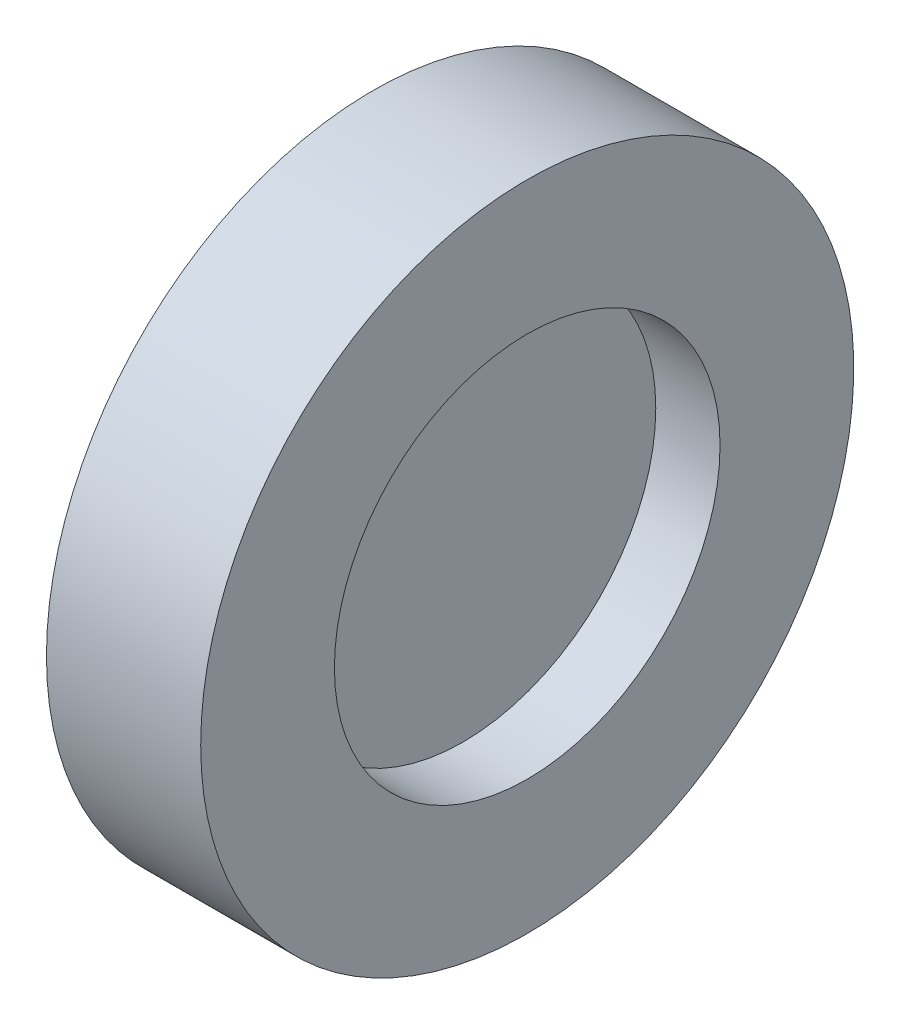
from build123d import *

# Parameters (mm, degrees)
SKETCH_1_W = 1
SKETCH_1_H = 7.5
SKETCH_4_W = 6
SKETCH_4_H = 5.2


with BuildPart() as part:
    # 草图1 → 旋转2 (revolve)
    with BuildSketch(Plane.XY, mode=Mode.PRIVATE) as revolve_2_sk:
        with Locations((0, 3.75)):
            Rectangle(SKETCH_1_W, SKETCH_1_H)
    revolve(revolve_2_sk.sketch.rotate(Axis((-0.5, 0, 0), (1, 0, 0)), 90), axis=Axis((-0.5, 0, 0), (1, 0, 0)))  # turned: the seam where the file's is

    # 草图4 → 旋转3 (revolve)
    with BuildSketch(Plane.XY, mode=Mode.PRIVATE) as revolve_3_sk:
        with Locations((0, 10.1)):
            Rectangle(SKETCH_4_W, SKETCH_4_H)
    revolve(revolve_3_sk.sketch.rotate(Axis((-1.614212419, 0, 0), (1, 0, 0)), 90), axis=Axis((-1.614212419, 0, 0), (1, 0, 0)))  # turned: the seam where the file's is


solid = part.part
